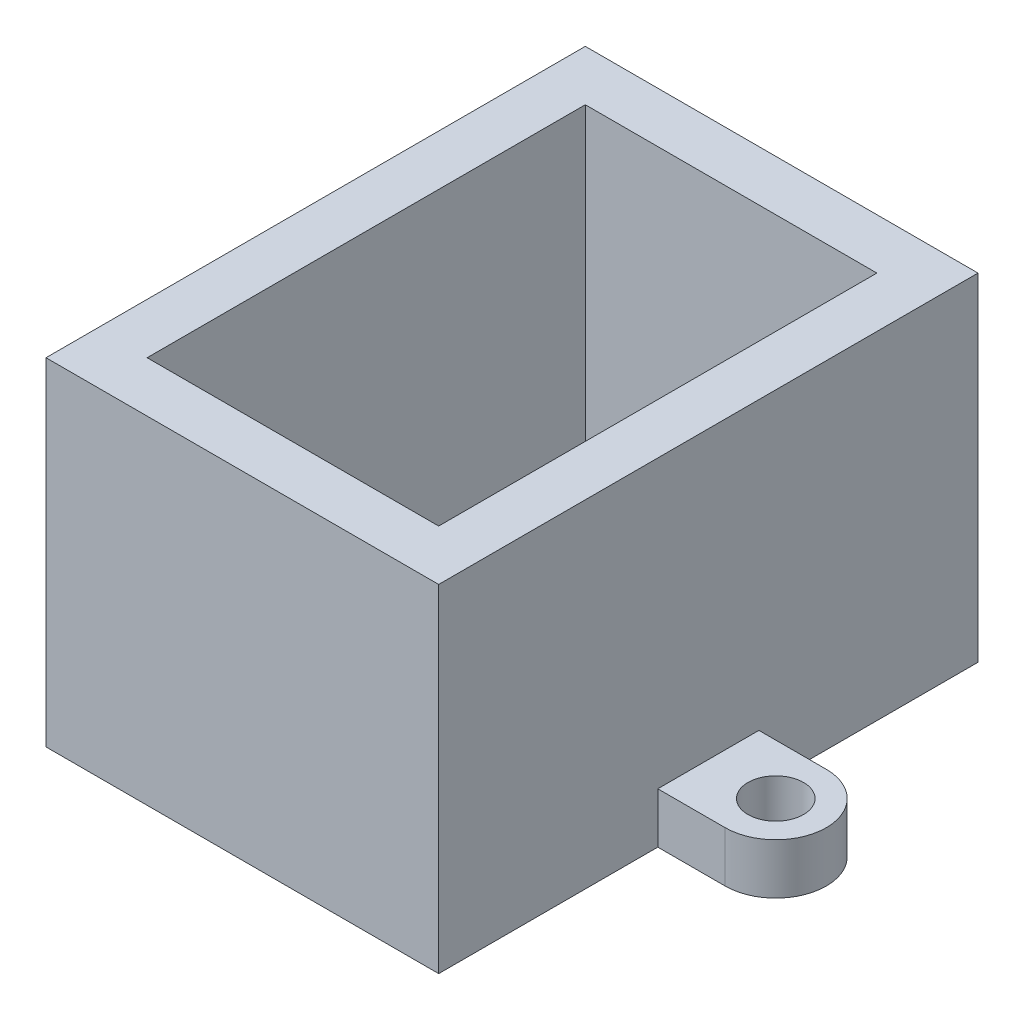
from build123d import *

# Parameters (mm, degrees)
SKETCH1_W           = 23.3
SKETCH1_H           = 32
SKETCH1_W_2         = 17.3
SKETCH1_H_2         = 26
BOSS_EXTRUDE1_DEPTH = 20
SKETCH3_R           = 1.65
BOSS_EXTRUDE2_DEPTH = 3


with BuildPart() as part:
    # Sketch1 → Boss-Extrude1 (new body)
    with BuildSketch(Plane(origin=(0, 0, 0), x_dir=(1, 0, 0), z_dir=(0, 1, 0))):
        Rectangle(SKETCH1_W, SKETCH1_H)
        Rectangle(SKETCH1_W_2, SKETCH1_H_2, mode=Mode.SUBTRACT)
    extrude(amount=BOSS_EXTRUDE1_DEPTH)

    # Sketch3 → Boss-Extrude2 (add)
    with BuildSketch(Plane(origin=(0, 0, 0), x_dir=(1, 0, 0), z_dir=(0, 1, 0))):
        with BuildLine():
            Line((11.65, 3), (15.65, 3))
            ThreePointArc((15.65, 3), (18.65, 0), (15.65, -3))
            Line((15.65, -3), (11.65, -3))
            Line((11.65, -3), (11.65, 3))
        make_face()
        with Locations((15.65, 0)):
            Circle(SKETCH3_R, mode=Mode.SUBTRACT)
        with BuildLine():
            Line((-11.65, -3), (-15.65, -3))
            ThreePointArc((-15.65, -3), (-18.65, 0), (-15.65, 3))
            Line((-15.65, 3), (-11.65, 3))
            Line((-11.65, 3), (-11.65, -3))
        make_face()
        with Locations((-15.65, 0)):
            Circle(SKETCH3_R, mode=Mode.SUBTRACT)
    extrude(amount=BOSS_EXTRUDE2_DEPTH)


solid = part.part
